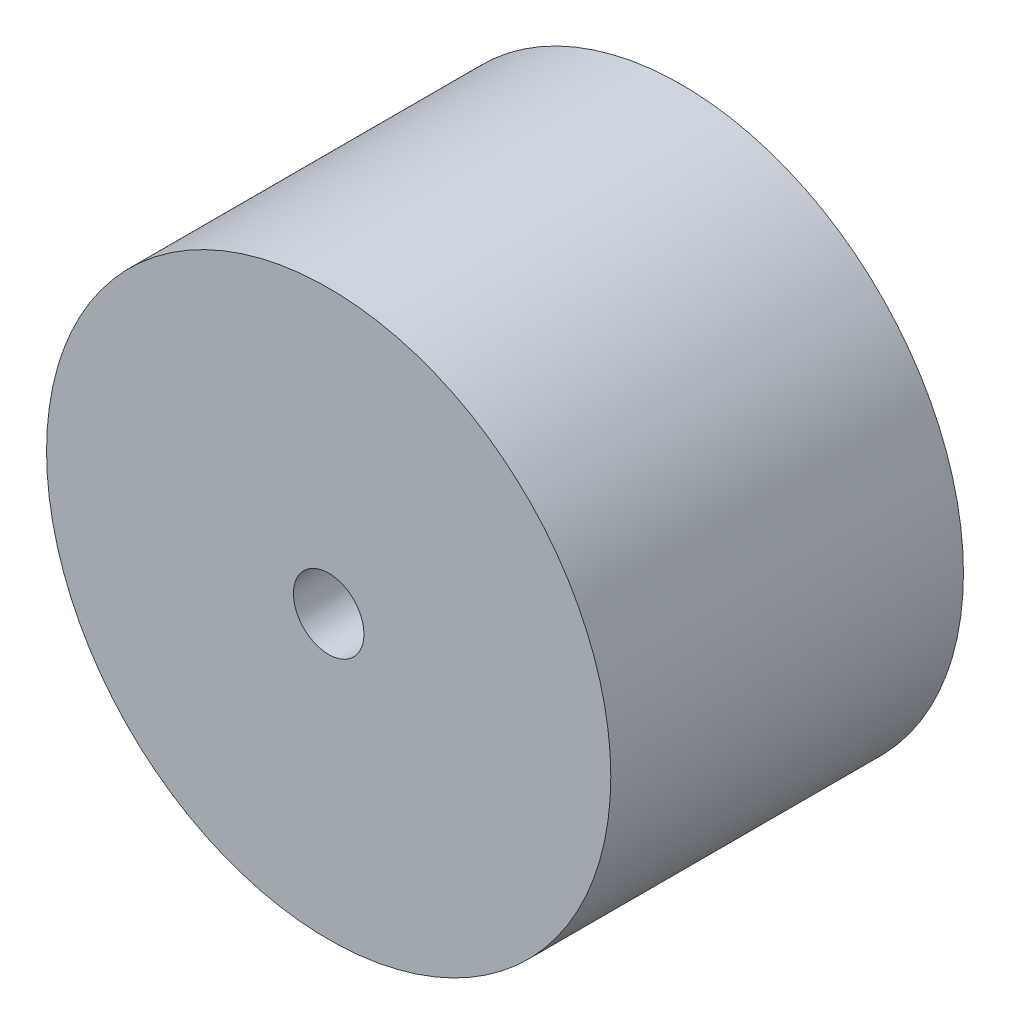
from build123d import *

# Parameters (mm, degrees)
SKETCH1_R           = 40
SKETCH1_R_2         = 5
BOSS_EXTRUDE1_DEPTH = 50


with BuildPart() as part:
    # Sketch1 → Boss-Extrude1 (new body)
    with BuildSketch(Plane.XY):
        Circle(SKETCH1_R)
        Circle(SKETCH1_R_2, mode=Mode.SUBTRACT)
    extrude(amount=BOSS_EXTRUDE1_DEPTH)


solid = part.part
